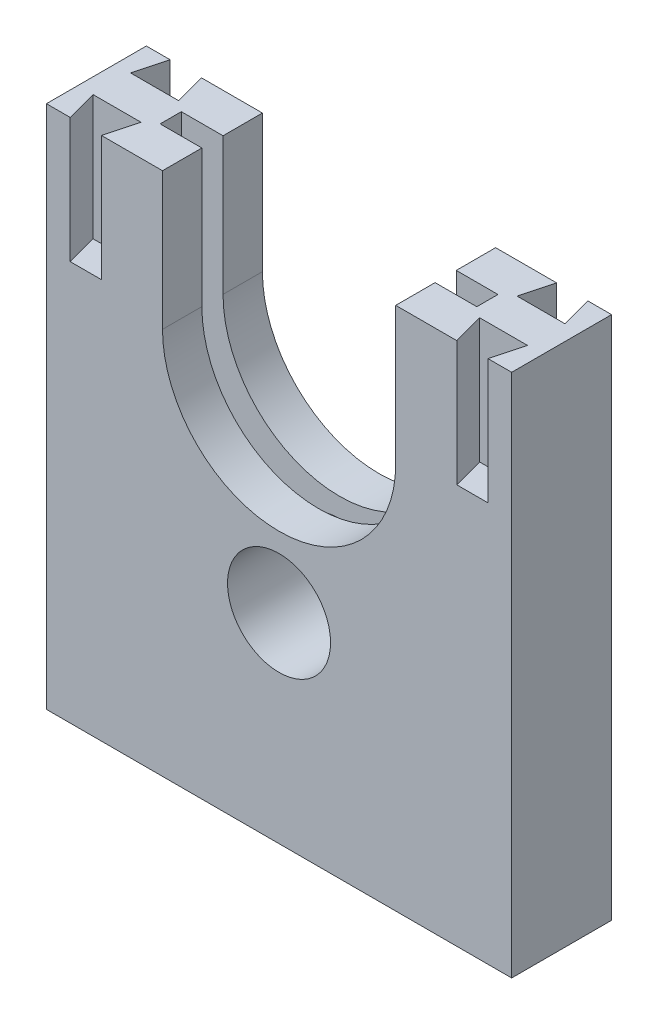
from build123d import *

# Parameters (mm, degrees)
SKETCH2_W           = 36
SKETCH2_H           = 42
BOSS_EXTRUDE1_DEPTH = 8
CUT_EXTRUDE1_DEPTH  = 10
CUT_EXTRUDE2_DEPTH  = 10
SKETCH5_W           = 25.353942038
SKETCH5_H           = 1.695405108
CUT_EXTRUDE3_DEPTH  = 25
SKETCH6_R           = 4.125
CUT_EXTRUDE4_DEPTH  = 7.1
SKETCH7_W           = 0.63
SKETCH7_H           = 8
SKETCH7_W_2         = 0.620319398
BOSS_EXTRUDE2_DEPTH = 42


with BuildPart() as part:
    # Sketch2 → Boss-Extrude1 (new body)
    with BuildSketch(Plane.XY):
        with Locations((-1.487179487, 11.461538462)):
            Rectangle(SKETCH2_W, SKETCH2_H)
    extrude(amount=BOSS_EXTRUDE1_DEPTH)

    # Sketch3 → Cut-Extrude1 (cut)
    with BuildSketch(Plane(origin=(0, 32.461538462, 0), x_dir=(1, 0, 0), z_dir=(0, 1, 0))):
        Polygon((-18.212179487, 0), (-18.882052468, -2.5), (-15.042306506, -2.5), (-15.712179487, 0), align=None)
        Polygon((-18.212179487, -8), (-18.882052468, -5.5), (-15.042306506, -5.5), (-15.712179487, -8), align=None)
        Polygon((15.237820513, 0), (15.907693494, -2.5), (12.067947532, -2.5), (12.737820513, 0), align=None)
        Polygon((15.237820513, -8), (15.907693494, -5.5), (12.067947532, -5.5), (12.737820513, -8), align=None)
    extrude(amount=-CUT_EXTRUDE1_DEPTH, mode=Mode.SUBTRACT)

    # Sketch4 → Cut-Extrude2 (cut)
    with BuildSketch(Plane.XY.offset(8)):
        with BuildLine():
            Line((-10.823469947, 32.461538462), (7.849110972, 32.461538462))
            Line((7.849110972, 32.461538462), (7.849110972, 21.461538462))
            ThreePointArc((7.849110972, 21.461538462), (-1.487179487, 12.125248002), (-10.823469947, 21.461538462))
            Line((-10.823469947, 21.461538462), (-10.823469947, 32.461538462))
        make_face()
    extrude(amount=-CUT_EXTRUDE2_DEPTH, mode=Mode.SUBTRACT)

    # Sketch5 → Cut-Extrude3 (cut)
    with BuildSketch(Plane(origin=(0, 32.461538462, 0), x_dir=(1, 0, 0), z_dir=(0, 1, 0))):
        with Locations((-1.487179487, -4)):
            Rectangle(SKETCH5_W, SKETCH5_H)
    extrude(amount=-CUT_EXTRUDE3_DEPTH, mode=Mode.SUBTRACT)

    # Sketch6 → Cut-Extrude4 (cut)
    with BuildSketch(Plane.XY.offset(8)):
        with Locations((-1.491860089, 6.461538462)):
            Circle(SKETCH6_R)
    extrude(amount=-CUT_EXTRUDE4_DEPTH, mode=Mode.SUBTRACT)

    # Sketch7 → Boss-Extrude2 (add)
    with BuildSketch(Plane(origin=(0, 32.461538462, 0), x_dir=(1, 0, 0), z_dir=(0, 1, 0))):
        with Locations((-19.802179487, -4)):
            Rectangle(SKETCH7_W, SKETCH7_H)
        with Locations((16.822980212, -4)):
            Rectangle(SKETCH7_W_2, SKETCH7_H)
    extrude(amount=-BOSS_EXTRUDE2_DEPTH)


solid = part.part
